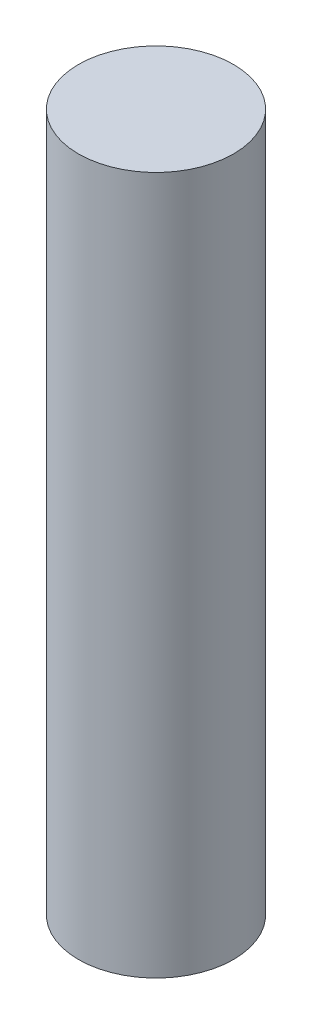
from build123d import *

# Parameters (mm, degrees)
AXLE_DIAMETER_R    = 12.7
AXLE_EXTRUDE_DEPTH = 114.3


with BuildPart() as part:
    # Axle Diameter → Axle Extrude (new body)
    with BuildSketch(Plane(origin=(0, 0, 0), x_dir=(1, 0, 0), z_dir=(0, 1, 0))):
        Circle(AXLE_DIAMETER_R)
    extrude(amount=AXLE_EXTRUDE_DEPTH)


solid = part.part
